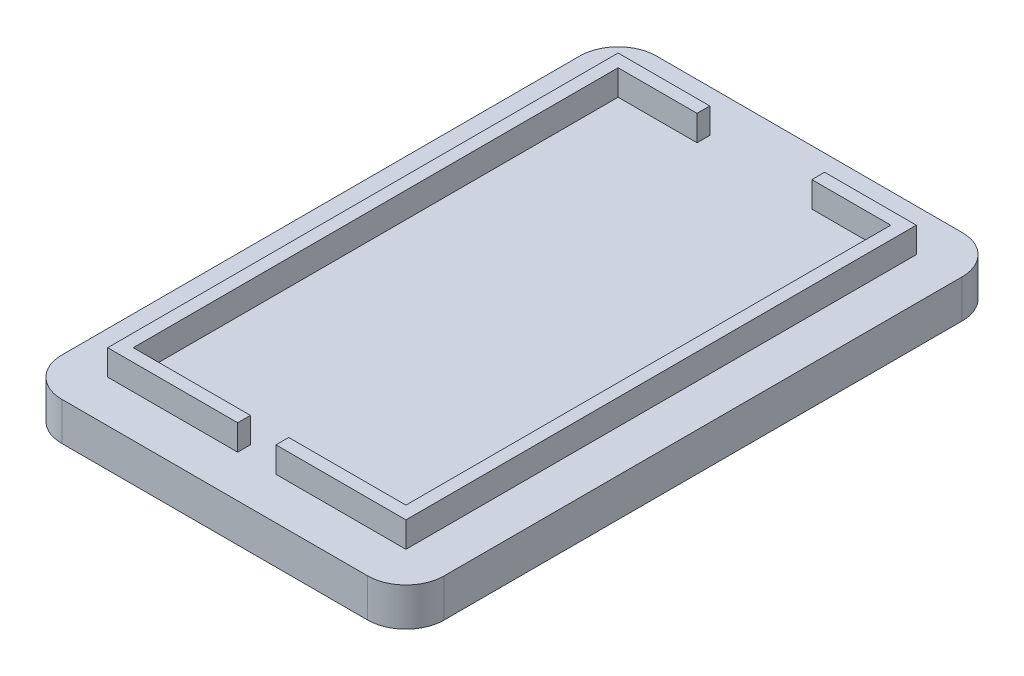
from build123d import *

# Parameters (mm, degrees)
SKETCH1_W           = 29.97
SKETCH1_H           = 46.6
BOSS_EXTRUDE1_DEPTH = 3
BOSS_EXTRUDE2_DEPTH = 2
FILLET1_R           = 3


with BuildPart() as part:
    # Sketch1 → Boss-Extrude1 (new body)
    with BuildSketch(Plane(origin=(0, 0, 0), x_dir=(1, 0, 0), z_dir=(0, 1, 0))):
        Rectangle(SKETCH1_W, SKETCH1_H)
    extrude(amount=BOSS_EXTRUDE1_DEPTH)

    # Sketch2 → Boss-Extrude2 (add)
    with BuildSketch(Plane(origin=(0, 3, 0), x_dir=(1, 0, 0), z_dir=(0, 1, 0))):
        Polygon((-4.5, 19), (-4.5, 20), (-11.685, 20), (-11.685, -20), (-1.5, -20), (-1.5, -19), (-10.685, -19), (-10.685, 19), align=None)
        Polygon((11.685, -20), (11.685, 20), (4.5, 20), (4.5, 19), (10.685, 19), (10.685, -19), (1.5, -19), (1.5, -20), align=None)
    extrude(amount=BOSS_EXTRUDE2_DEPTH)

    # Fillet1
    fillet1_edges = [part.edges().sort_by_distance(p)[0] for p in [
        (14.985, 1.5, -23.3),
        (14.985, 1.5, 23.3),
        (-14.985, 1.5, 23.3),
        (-14.985, 1.5, -23.3),
    ]]
    fillet(fillet1_edges, radius=FILLET1_R)


solid = part.part
